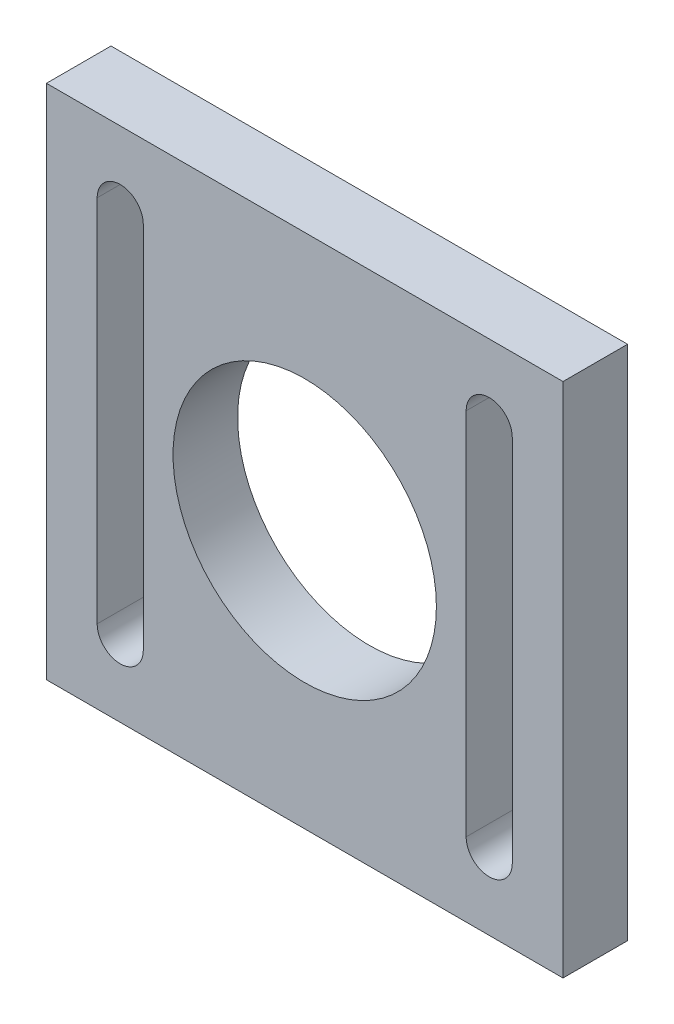
from build123d import *

# Parameters (mm, degrees)
SKETCH1_W           = 56
SKETCH1_H           = 56
BOSS_EXTRUDE1_DEPTH = 7
SKETCH2_R           = 14.275
CUT_EXTRUDE1_DEPTH  = 8


with BuildPart() as part:
    # Sketch1 → Boss-Extrude1 (new body)
    with BuildSketch(Plane.XY):
        with Locations((28, 28)):
            Rectangle(SKETCH1_W, SKETCH1_H)
    extrude(amount=BOSS_EXTRUDE1_DEPTH)

    # Sketch2 → Cut-Extrude1 (cut, through all)
    with BuildSketch(Plane.XY.offset(7)):
        with Locations((28, 28)):
            Circle(SKETCH2_R)
        with BuildLine():
            Line((10.5, 48), (10.5, 8))
            ThreePointArc((10.5, 8), (8, 5.5), (5.5, 8))
            Line((5.5, 8), (5.5, 48))
            ThreePointArc((5.5, 48), (8, 50.5), (10.5, 48))
        make_face()
        with BuildLine():
            Line((50.5, 48), (50.5, 8))
            ThreePointArc((50.5, 8), (48, 5.5), (45.5, 8))
            Line((45.5, 8), (45.5, 48))
            ThreePointArc((45.5, 48), (48, 50.5), (50.5, 48))
        make_face()
    extrude(amount=-CUT_EXTRUDE1_DEPTH, mode=Mode.SUBTRACT)


solid = part.part
